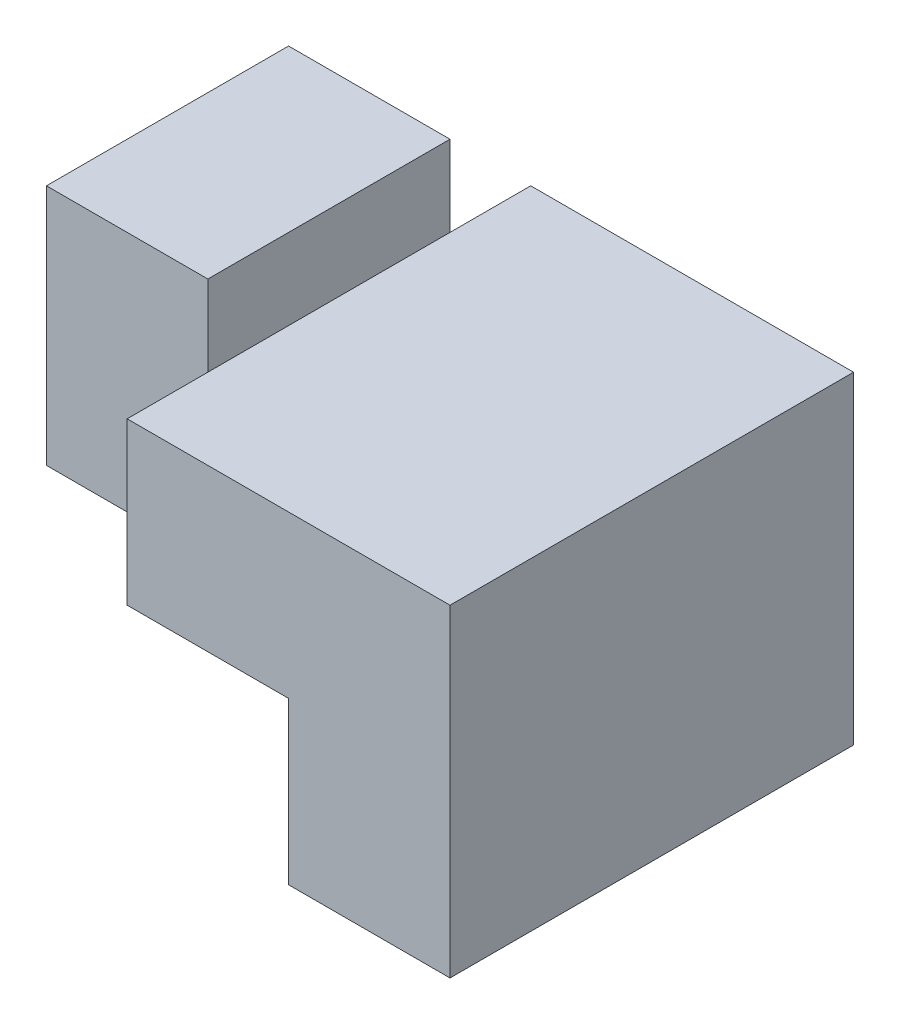
from build123d import *

# Parameters (mm, degrees)
SKETCH1_W           = 30
SKETCH1_H           = 25
BOSS_EXTRUDE1_DEPTH = 25
SKETCH2_W           = 10
SKETCH2_H           = 10
CUT_EXTRUDE3_DEPTH  = 10
SKETCH4_W           = 10
SKETCH4_H           = 5
CUT_EXTRUDE4_DEPTH  = 25
SKETCH5_W           = 10
SKETCH5_H           = 10
CUT_EXTRUDE5_DEPTH  = 10
SKETCH6_W           = 20
SKETCH6_H           = 5
CUT_EXTRUDE6_DEPTH  = 25
SKETCH7_W           = 10
SKETCH7_H           = 5
CUT_EXTRUDE7_DEPTH  = 25
SKETCH8_W           = 10
SKETCH8_H           = 5
CUT_EXTRUDE8_DEPTH  = 5
SKETCH9_W           = 10
SKETCH9_H           = 5
CUT_EXTRUDE9_DEPTH  = 5


with BuildPart() as part:
    # Sketch1 → Boss-Extrude1 (new body)
    with BuildSketch(Plane.XY):
        with Locations((15, 12.5)):
            Rectangle(SKETCH1_W, SKETCH1_H)
    extrude(amount=BOSS_EXTRUDE1_DEPTH)

    # Sketch2 → Cut-Extrude3 (cut)
    with BuildSketch(Plane.XY.offset(25)):
        with Locations((5, 5)):
            Rectangle(SKETCH2_W, SKETCH2_H)
    extrude(amount=-CUT_EXTRUDE3_DEPTH, mode=Mode.SUBTRACT)

    # Sketch4 → Cut-Extrude4 (cut)
    with BuildSketch(Plane.XY.offset(25)):
        with Locations((15, 2.5)):
            Rectangle(SKETCH4_W, SKETCH4_H)
    extrude(amount=-CUT_EXTRUDE4_DEPTH, mode=Mode.SUBTRACT)

    # Sketch5 → Cut-Extrude5 (cut)
    with BuildSketch(Plane(origin=(0, 0, 0), x_dir=(-1, 0, 0), z_dir=(0, 0, -1))):
        with Locations((-5, 5)):
            Rectangle(SKETCH5_W, SKETCH5_H)
    extrude(amount=-CUT_EXTRUDE5_DEPTH, mode=Mode.SUBTRACT)

    # Sketch6 → Cut-Extrude6 (cut)
    with BuildSketch(Plane.XY.offset(25)):
        with Locations((20, 22.5)):
            Rectangle(SKETCH6_W, SKETCH6_H)
    extrude(amount=-CUT_EXTRUDE6_DEPTH, mode=Mode.SUBTRACT)

    # Sketch7 → Cut-Extrude7 (cut)
    with BuildSketch(Plane(origin=(0, 25, 0), x_dir=(1, 0, 0), z_dir=(0, 1, 0))):
        with Locations((5, -2.5)):
            Rectangle(SKETCH7_W, SKETCH7_H)
        with Locations((5, -22.5)):
            Rectangle(SKETCH7_W, SKETCH7_H)
    extrude(amount=-CUT_EXTRUDE7_DEPTH, mode=Mode.SUBTRACT)

    # Sketch8 → Cut-Extrude8 (cut)
    with BuildSketch(Plane.XY.offset(25)):
        with Locations((15, 7.5)):
            Rectangle(SKETCH8_W, SKETCH8_H)
    extrude(amount=-CUT_EXTRUDE8_DEPTH, mode=Mode.SUBTRACT)

    # Sketch9 → Cut-Extrude9 (cut)
    with BuildSketch(Plane(origin=(0, 0, 0), x_dir=(-1, 0, 0), z_dir=(0, 0, -1))):
        with Locations((-15, 7.5)):
            Rectangle(SKETCH9_W, SKETCH9_H)
    extrude(amount=-CUT_EXTRUDE9_DEPTH, mode=Mode.SUBTRACT)


solid = part.part
